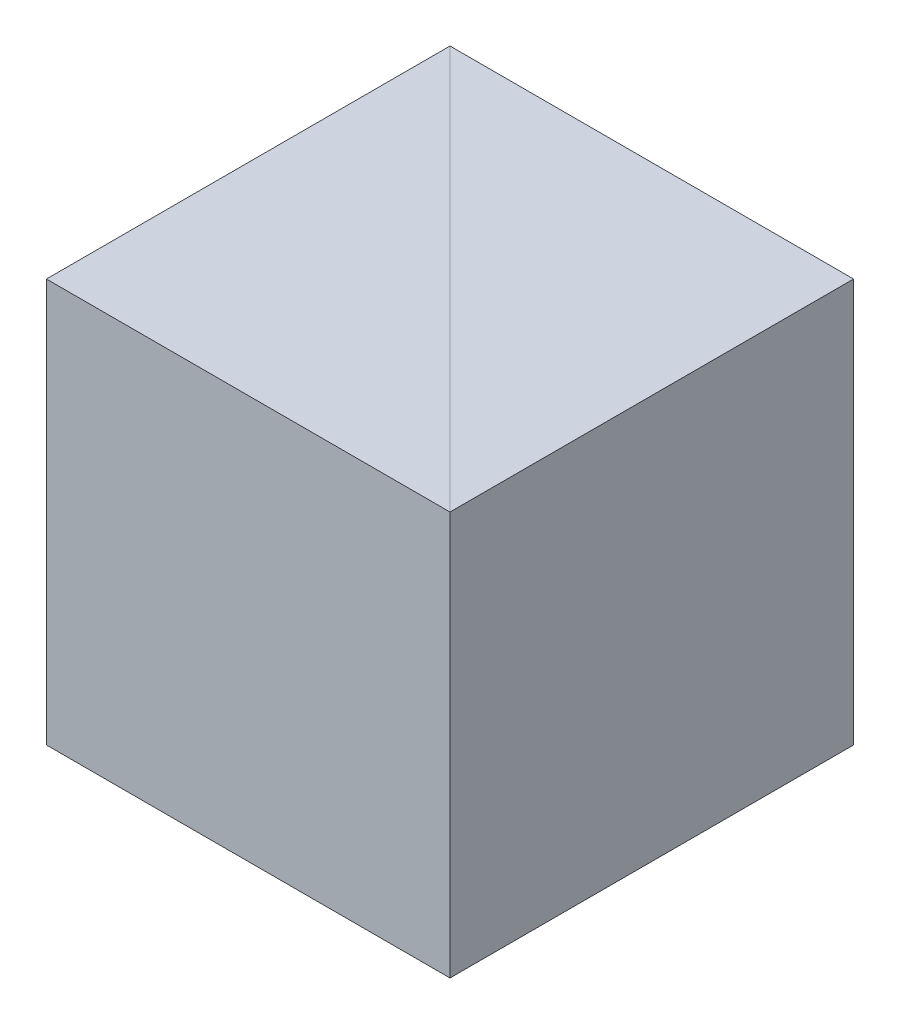
from build123d import *

# Parameters (mm, degrees)
EXTRUDE_1_DEPTH = 20
EXTRUDE_2_DEPTH = 20


with BuildPart() as part:
    # 草图1 → 凸台-拉伸1 (new body)
    with BuildSketch(Plane(origin=(0, 0, 0), x_dir=(1, 0, 0), z_dir=(0, 1, 0))):
        Polygon((0, 0), (0, 20), (-20, 20), align=None)
    extrude(amount=EXTRUDE_1_DEPTH)


with BuildPart() as body_2:
    # 草图2 → 凸台-拉伸2 (new body)
    with BuildSketch(Plane.XZ):
        Polygon((-20, -20), (-20, 0), (0, 0), align=None)
    extrude(amount=-EXTRUDE_2_DEPTH)


solid = Compound([part.part, body_2.part])
